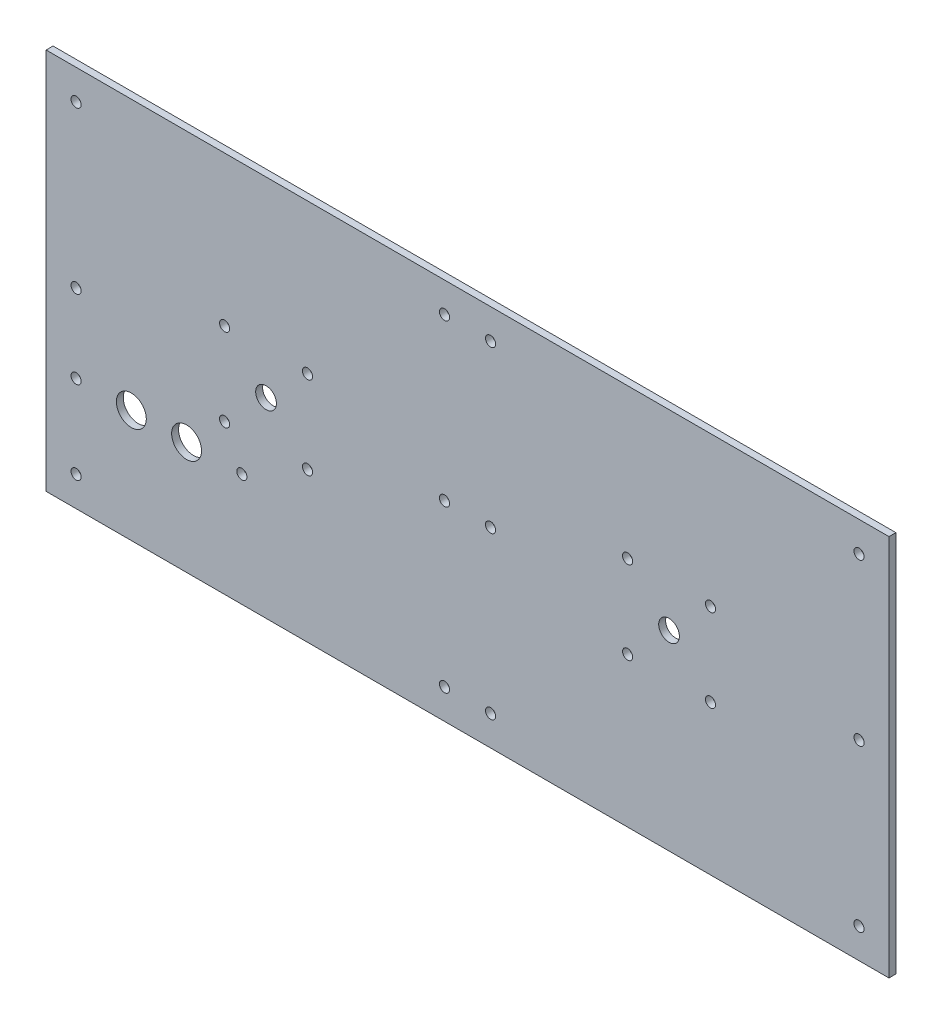
from build123d import *

# Parameters (mm, degrees)
ESQUISSE1_W        = 366
ESQUISSE1_H        = 166
ESQUISSE1_R        = 2.2
ESQUISSE1_R_2      = 4.5
ESQUISSE1_R_3      = 6.5
BOSS_EXTRU_1_DEPTH = 3


with BuildPart() as part:
    # Esquisse1 → Boss.-Extru.1 (new body)
    with BuildSketch(Plane.XY):
        with Locations((183, 83)):
            Rectangle(ESQUISSE1_W, ESQUISSE1_H)
        with Locations((13, 153)):
            Circle(ESQUISSE1_R, mode=Mode.SUBTRACT)
        with Locations((13, 13)):
            Circle(ESQUISSE1_R, mode=Mode.SUBTRACT)
        with Locations((13, 83)):
            Circle(ESQUISSE1_R, mode=Mode.SUBTRACT)
        with Locations((173, 153)):
            Circle(ESQUISSE1_R, mode=Mode.SUBTRACT)
        with Locations((193, 83)):
            Circle(ESQUISSE1_R, mode=Mode.SUBTRACT)
        with Locations((173, 83)):
            Circle(ESQUISSE1_R, mode=Mode.SUBTRACT)
        with Locations((193, 153)):
            Circle(ESQUISSE1_R, mode=Mode.SUBTRACT)
        with Locations((353, 83)):
            Circle(ESQUISSE1_R, mode=Mode.SUBTRACT)
        with Locations((353, 13)):
            Circle(ESQUISSE1_R, mode=Mode.SUBTRACT)
        with Locations((353, 153)):
            Circle(ESQUISSE1_R, mode=Mode.SUBTRACT)
        with Locations((193, 13)):
            Circle(ESQUISSE1_R, mode=Mode.SUBTRACT)
        with Locations((173, 13)):
            Circle(ESQUISSE1_R, mode=Mode.SUBTRACT)
        with Locations((270.5, 83)):
            Circle(ESQUISSE1_R_2, mode=Mode.SUBTRACT)
        with Locations((95.5, 83)):
            Circle(ESQUISSE1_R_2, mode=Mode.SUBTRACT)
        with Locations((77.5, 101)):
            Circle(ESQUISSE1_R, mode=Mode.SUBTRACT)
        with Locations((113.5, 101)):
            Circle(ESQUISSE1_R, mode=Mode.SUBTRACT)
        with Locations((77.5, 65)):
            Circle(ESQUISSE1_R, mode=Mode.SUBTRACT)
        with Locations((113.5, 65)):
            Circle(ESQUISSE1_R, mode=Mode.SUBTRACT)
        with Locations((288.5, 65)):
            Circle(ESQUISSE1_R, mode=Mode.SUBTRACT)
        with Locations((252.5, 65)):
            Circle(ESQUISSE1_R, mode=Mode.SUBTRACT)
        with Locations((252.5, 101)):
            Circle(ESQUISSE1_R, mode=Mode.SUBTRACT)
        with Locations((288.5, 101)):
            Circle(ESQUISSE1_R, mode=Mode.SUBTRACT)
        with Locations((37, 49)):
            Circle(ESQUISSE1_R_3, mode=Mode.SUBTRACT)
        with Locations((61, 49)):
            Circle(ESQUISSE1_R_3, mode=Mode.SUBTRACT)
        with Locations((85, 49)):
            Circle(ESQUISSE1_R, mode=Mode.SUBTRACT)
        with Locations((13, 49)):
            Circle(ESQUISSE1_R, mode=Mode.SUBTRACT)
    extrude(amount=BOSS_EXTRU_1_DEPTH)


solid = part.part
